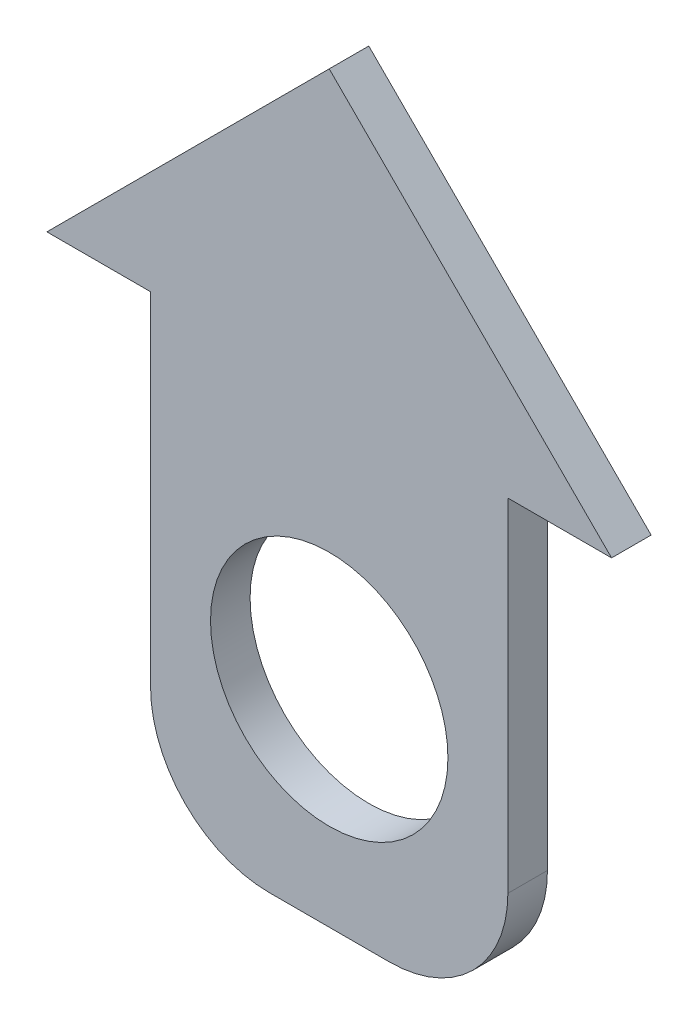
from build123d import *

# Parameters (mm, degrees)
SKETCH1_R           = 3
BOSS_EXTRUDE1_DEPTH = 1
FILLET1_R           = 3
BOSS_EXTRUDE2_DEPTH = 1


with BuildPart() as part:
    # Sketch1 → Boss-Extrude1 (new body)
    with BuildSketch(Plane.XY):
        Polygon((-4.515055907, -5.207968635), (4.515055907, -5.207968635), (4.515055907, 6.442798737), (7.135711465, 6.442798737), (0, 13.578510202), (-7.135711465, 6.442798737), (-4.515055907, 6.442798737), align=None)
        Circle(SKETCH1_R, mode=Mode.SUBTRACT)
    extrude(amount=BOSS_EXTRUDE1_DEPTH)

    # Fillet1
    fillet1_edges = [part.edges().sort_by_distance(p)[0] for p in [
        (4.515055907, -5.207968635, 0.5),
        (-4.515055907, -5.207968635, 0.5),
    ]]
    fillet(fillet1_edges, radius=FILLET1_R)

    # Sketch2 → Boss-Extrude2 (add)
    with BuildSketch(Plane(origin=(0, 0, 0), x_dir=(-1, 0, 0), z_dir=(0, 0, -1))):
        with BuildLine():
            ThreePointArc((0, 3), (0.507305936, 2.956795679), (1, 2.828427125))
            Line((1, 2.828427125), (1, 4.210117693))
            Line((1, 4.210117693), (0, 4.210117693))
            Line((0, 4.210117693), (0, 3))
        make_face()
        with BuildLine():
            ThreePointArc((-1, 2.828427125), (-0.507305936, 2.956795679), (0, 3))
            Line((0, 3), (0, 4.210117693))
            Line((0, 4.210117693), (-1, 4.210117693))
            Line((-1, 4.210117693), (-1, 2.828427125))
        make_face()
    extrude(amount=BOSS_EXTRUDE2_DEPTH)


solid = part.part
